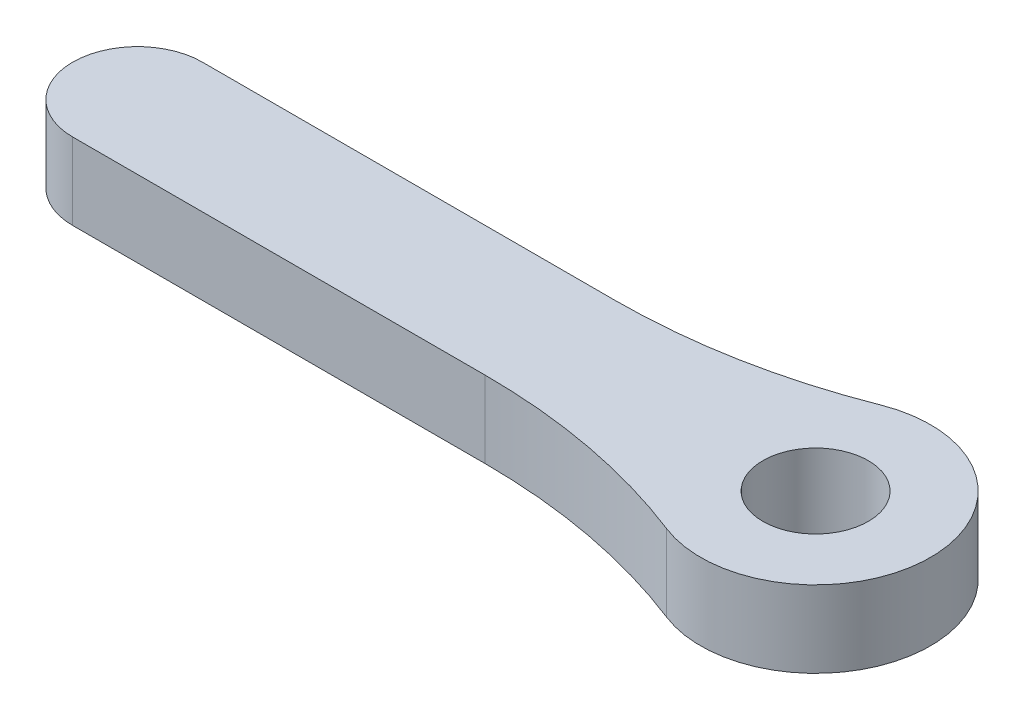
from build123d import *

# Parameters (mm, degrees)
BOSS_EXTRUDE1_DEPTH              = 3.175
F_11_64_0_17188_DIAMETER_HOLE1_D = 4.365752
FILLET1_R                        = 25.4


with BuildPart() as part:
    # Sketch1 → Boss-Extrude1 (new body)
    with BuildSketch(Plane(origin=(0, 0, 0), x_dir=(1, 0, 0), z_dir=(0, 1, 0))):
        with BuildLine():
            Line((-3.932886418, -2.685853807), (-25.4, -2.685853807))
            Line((-25.4, -2.685853807), (-28.085853807, -2.685853807))
            ThreePointArc((-28.085853807, -2.685853807), (-30.771707615, 0), (-28.085853807, 2.685853807))
            Line((-28.085853807, 2.685853807), (-25.4, 2.685853807))
            Line((-25.4, 2.685853807), (-3.932886418, 2.685853807))
            ThreePointArc((-3.932886418, 2.685853807), (4.7625, 0), (-3.932886418, -2.685853807))
        make_face()
    extrude(amount=BOSS_EXTRUDE1_DEPTH)

    # 11/64 (0.17188) Diameter Hole1 (through all)
    with Locations(Plane(origin=(0, 3.175, 0), x_dir=(1, 0, 0), z_dir=(0, 1, 0))):
        with Locations((0, 0)):
            Hole(F_11_64_0_17188_DIAMETER_HOLE1_D / 2)

    # Fillet1
    fillet1_edges = [part.edges().sort_by_distance(p)[0] for p in [
        (-3.932886418, 1.5875, -2.685853807),
        (-3.932886418, 1.5875, 2.685853807),
    ]]
    fillet(fillet1_edges, radius=FILLET1_R)


solid = part.part
